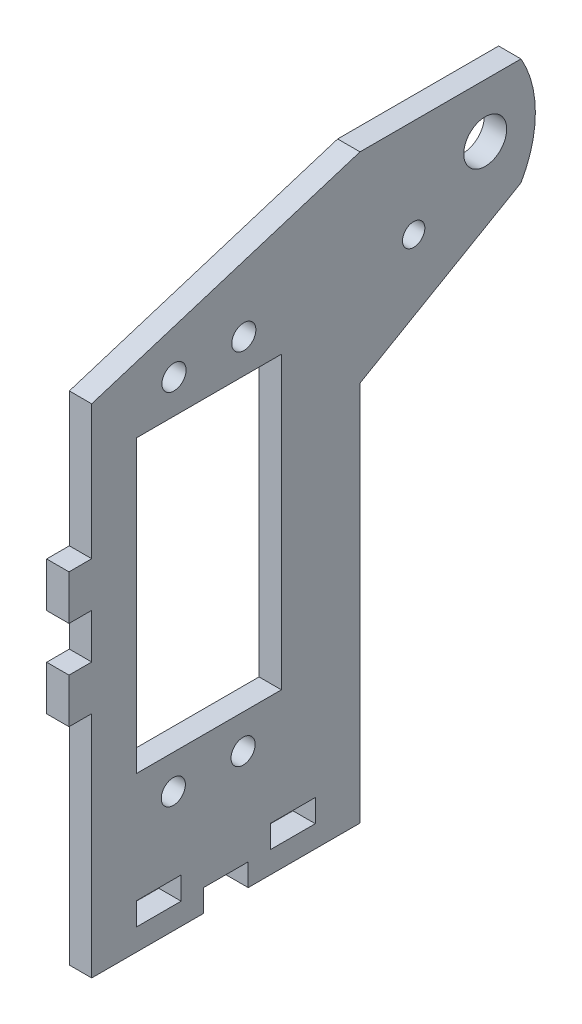
from build123d import *

# Parameters (mm, degrees)
BOSS_EXTRUDE1_DEPTH                 = 3.175
SKETCH2_R                           = 1.7145
SKETCH2_W                           = 20.586
SKETCH2_H                           = 41.275
CUT_FOR_MOTOR_DEPTH                 = 4.175
SKETCH3_R                           = 3.048
CUT_FOR_AXLE_DEPTH                  = 4.175
SKETCH4_W                           = 6.35
SKETCH4_H                           = 3.2258
CUT_FOR_TABS_DEPTH                  = 4.175
CUT_EXTRUDE6_DEPTH                  = 4.175
SKETCH9_W                           = 3.2258
SKETCH9_H                           = 6.35
TABS_FOR_BACK_PLATE_DEPTH           = 3.175
SKETCH10_R                          = 1.5875
CUT_FOR_BASIC_TILT_LOCK_SCREW_DEPTH = 4.175


with BuildPart() as part:
    # Sketch1 → Boss-Extrude1 (new body)
    with BuildSketch(Plane(origin=(0, 0, 0), x_dir=(0, 0, -1), z_dir=(1, 0, 0))):
        with BuildLine():
            Line((-8.901335672, 27.917328656), (29.198664328, 27.917328656))
            Line((29.198664328, 27.917328656), (52.058664328, 27.917328656))
            ThreePointArc((52.058664328, 27.917328656), (54.100437174, 20.297328656), (52.058664328, 12.677328656))
            Line((52.058664328, 12.677328656), (29.198664328, -0.520898498))
            Line((29.198664328, -0.520898498), (29.198664328, -54.632671344))
            Line((29.198664328, -54.632671344), (-8.901335672, -54.632671344))
            Line((-8.901335672, -54.632671344), (-8.901335672, 27.917328656))
        make_face()
    extrude(amount=BOSS_EXTRUDE1_DEPTH)

    # Sketch2 → cut for motor (cut, through all)
    with BuildSketch(Plane(origin=(3.175, 0, 0), x_dir=(0, 0, -1), z_dir=(1, 0, 0))):
        with Locations((12.696664328, 13.439328656)):
            Circle(SKETCH2_R)
        with Locations((2.786664328, 13.439328656)):
            Circle(SKETCH2_R)
        with Locations((12.595457687, -37.487671344)):
            Circle(SKETCH2_R)
        with Locations((2.685457687, -37.487671344)):
            Circle(SKETCH2_R)
        with Locations((7.741664328, -12.024171344)):
            Rectangle(SKETCH2_W, SKETCH2_H)
    extrude(amount=-CUT_FOR_MOTOR_DEPTH, mode=Mode.SUBTRACT)

    # Sketch3 → cut for axle (cut, through all)
    with BuildSketch(Plane(origin=(3.175, 0, 0), x_dir=(0, 0, -1), z_dir=(1, 0, 0))):
        with Locations((46.978664328, 20.297328656)):
            Circle(SKETCH3_R)
    extrude(amount=-CUT_FOR_AXLE_DEPTH, mode=Mode.SUBTRACT)

    # Sketch4 → cut for tabs (cut, through all)
    with BuildSketch(Plane(origin=(3.175, 0, 0), x_dir=(0, 0, -1), z_dir=(1, 0, 0))):
        with Locations((0.623664328, -49.920971344)):
            Rectangle(SKETCH4_W, SKETCH4_H)
        with Locations((19.673664328, -49.920971344)):
            Rectangle(SKETCH4_W, SKETCH4_H)
        Polygon((10.148664328, -54.632671344), (13.323664328, -54.632671344), (13.323664328, -51.457671344), (6.973664328, -51.457671344), (6.973664328, -54.632671344), align=None)
    extrude(amount=-CUT_FOR_TABS_DEPTH, mode=Mode.SUBTRACT)

    # Sketch8 → Cut-Extrude6 (cut, through all)
    with BuildSketch(Plane(origin=(3.175, 0, 0), x_dir=(0, 0, -1), z_dir=(1, 0, 0))):
        Polygon((29.198664328, 27.917328656), (-8.901335672, 15.979328656), (-8.901335672, 27.917328656), align=None)
    extrude(amount=-CUT_EXTRUDE6_DEPTH, mode=Mode.SUBTRACT)

    # Sketch9 → tabs for back plate (add)
    with BuildSketch(Plane(origin=(3.175, 0, 0), x_dir=(0, 0, -1), z_dir=(1, 0, 0))):
        with Locations((-10.514235672, -6.245671344)):
            Rectangle(SKETCH9_W, SKETCH9_H)
        with Locations((-10.514235672, -18.945671344)):
            Rectangle(SKETCH9_W, SKETCH9_H)
    extrude(amount=-TABS_FOR_BACK_PLATE_DEPTH)

    # Sketch10 → cut for basic tilt lock screw (cut, through all)
    with BuildSketch(Plane(origin=(3.175, 0, 0), x_dir=(0, 0, -1), z_dir=(1, 0, 0))):
        with Locations((36.818664328, 13.947328656)):
            Circle(SKETCH10_R)
    extrude(amount=-CUT_FOR_BASIC_TILT_LOCK_SCREW_DEPTH, mode=Mode.SUBTRACT)


solid = part.part
